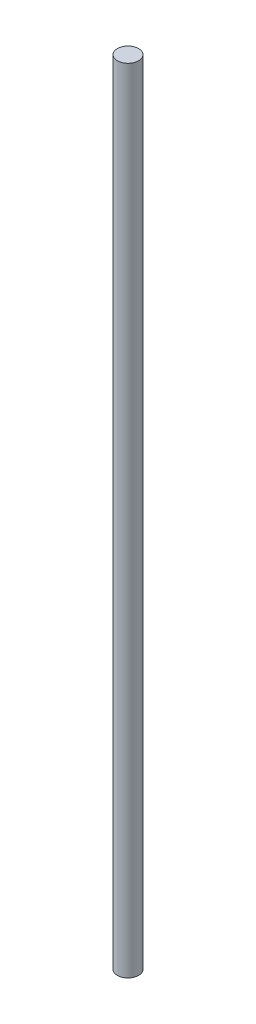
from build123d import *

# Parameters (mm, degrees)
SKETCH1_R           = 2.38125
BOSS_EXTRUDE1_DEPTH = 177.8


with BuildPart() as part:
    # Sketch1 → Boss-Extrude1 (new body)
    with BuildSketch(Plane(origin=(0, 0, 0), x_dir=(1, 0, 0), z_dir=(0, 1, 0))):
        Circle(SKETCH1_R)
    extrude(amount=BOSS_EXTRUDE1_DEPTH)


solid = part.part
